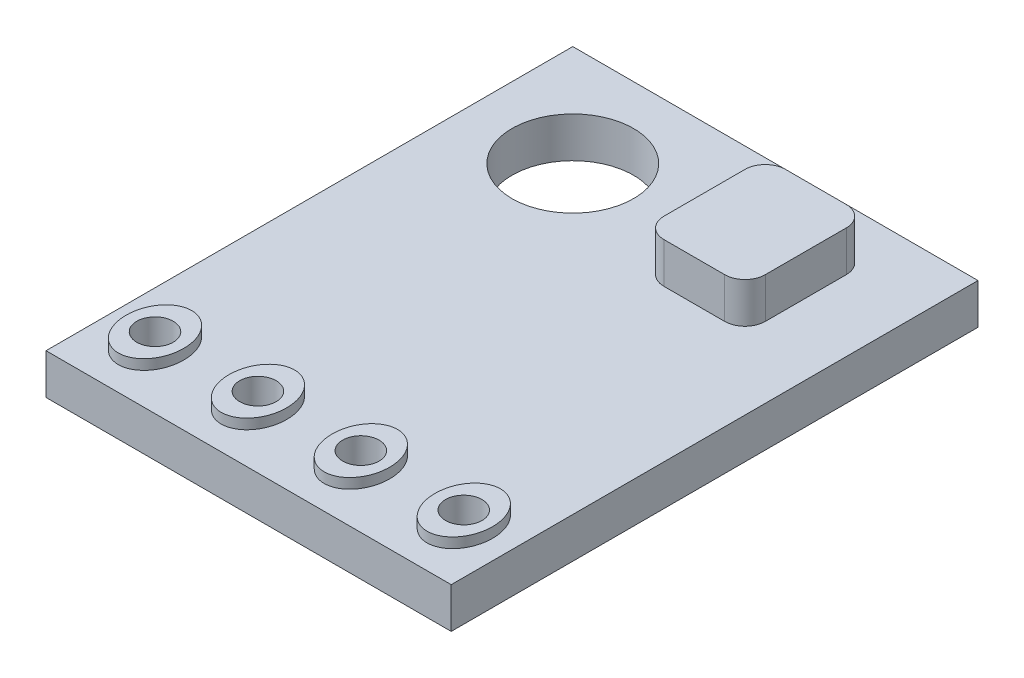
from build123d import *

# Parameters (mm, degrees)
SKETCH1_W               = 10
SKETCH1_H               = 13
SKETCH1_R               = 1.5
BOSS_EXTRUDE1_DEPTH     = 1
BOSS_EXTRUDE2_DEPTH     = 2
SKETCH3_RX              = 0.905906642
SKETCH3_RY              = 0.710654866
SKETCH3_R               = 0.45
BOSS_EXTRUDE3_DEPTH     = 1.25
SKETCH4_R               = 0.45
CUT_EXTRUDE1_DEPTH      = 3
CUT_EXTRUDE1_DEPTH_BACK = 2


with BuildPart() as part:
    # Sketch1 → Boss-Extrude1 (new body)
    with BuildSketch(Plane(origin=(0, 0, 0), x_dir=(1, 0, 0), z_dir=(0, 1, 0))):
        Rectangle(SKETCH1_W, SKETCH1_H)
        with Locations((-2.5, 4)):
            Circle(SKETCH1_R, mode=Mode.SUBTRACT)
    extrude(amount=BOSS_EXTRUDE1_DEPTH)

    # Sketch2 → Boss-Extrude2 (add)
    with BuildSketch(Plane(origin=(0, 0, 0), x_dir=(1, 0, 0), z_dir=(0, 1, 0))):
        with BuildLine():
            Line((1.25, 5.5), (2.75, 5.5))
            ThreePointArc((2.75, 5.5), (3.103553391, 5.353553391), (3.25, 5))
            Line((3.25, 5), (3.25, 3))
            ThreePointArc((3.25, 3), (3.103553391, 2.646446609), (2.75, 2.5))
            Line((2.75, 2.5), (1.25, 2.5))
            ThreePointArc((1.25, 2.5), (0.896446609, 2.646446609), (0.75, 3))
            Line((0.75, 3), (0.75, 5))
            ThreePointArc((0.75, 5), (0.896446609, 5.353553391), (1.25, 5.5))
        make_face()
    extrude(amount=BOSS_EXTRUDE2_DEPTH)

    # Sketch3 → Boss-Extrude3 (add)
    with BuildSketch(Plane(origin=(0, 0, 0), x_dir=(1, 0, 0), z_dir=(0, 1, 0))):
        with Locations(Location((-1.27, -5), (0, 0, -90))):
            Ellipse(SKETCH3_RX, SKETCH3_RY)
        with Locations((-1.27, -5)):
            Circle(SKETCH3_R, mode=Mode.SUBTRACT)
        with Locations(Location((-3.81, -5), (0, 0, -90))):
            Ellipse(SKETCH3_RX, SKETCH3_RY)
        with Locations((-3.81, -5)):
            Circle(SKETCH3_R, mode=Mode.SUBTRACT)
        with Locations(Location((3.81, -5), (0, 0, -90))):
            Ellipse(SKETCH3_RX, SKETCH3_RY)
        with Locations((3.81, -5)):
            Circle(SKETCH3_R, mode=Mode.SUBTRACT)
        with Locations(Location((1.27, -5), (0, 0, -90))):
            Ellipse(SKETCH3_RX, SKETCH3_RY)
        with Locations((1.27, -5)):
            Circle(SKETCH3_R, mode=Mode.SUBTRACT)
    extrude(amount=BOSS_EXTRUDE3_DEPTH)

    # Sketch4 → Cut-Extrude1 (cut, two sides)
    with BuildSketch(Plane(origin=(0, 0, 0), x_dir=(1, 0, 0), z_dir=(0, 1, 0))) as cut_extrude1_sk:
        with Locations((-3.81, -5)):
            Circle(SKETCH4_R)
        with Locations((-1.27, -5)):
            Circle(SKETCH4_R)
        with Locations((1.27, -5)):
            Circle(SKETCH4_R)
        with Locations((3.81, -5)):
            Circle(SKETCH4_R)
    extrude(amount=CUT_EXTRUDE1_DEPTH, mode=Mode.SUBTRACT)
    extrude(cut_extrude1_sk.sketch, amount=-CUT_EXTRUDE1_DEPTH_BACK, mode=Mode.SUBTRACT)


solid = part.part
